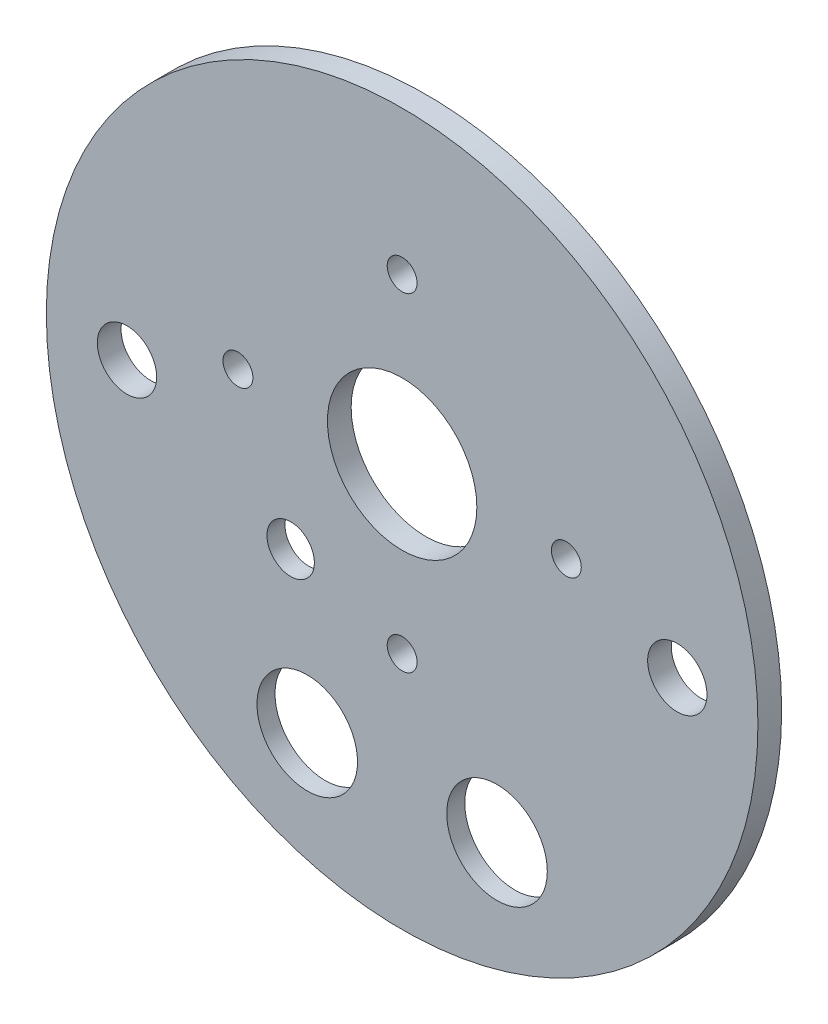
from build123d import *

# Parameters (mm, degrees)
SKETCH1_R           = 49.5046
BOSS_EXTRUDE1_DEPTH = 5.08
SKETCH2_R           = 47.625
BOSS_EXTRUDE2_DEPTH = 3.175
SKETCH3_R           = 6.731
SKETCH3_R_2         = 3.96875
SKETCH3_R_3         = 10
SKETCH3_R_4         = 2
SKETCH3_R_5         = 3.175
CUT_EXTRUDE1_DEPTH  = 9.255
SKETCH7_R           = 52.166274697
CUT_EXTRUDE4_DEPTH  = 5.08
SKETCH8_R           = 11.176
SKETCH8_R_2         = 6.35
CUT_EXTRUDE5_DEPTH  = 0.762


with BuildPart() as part:
    # Sketch1 → Boss-Extrude1 (new body)
    with BuildSketch(Plane.XY):
        Circle(SKETCH1_R)
    extrude(amount=BOSS_EXTRUDE1_DEPTH)

    # Sketch2 → Boss-Extrude2 (add)
    with BuildSketch(Plane.XY.offset(5.08)):
        Circle(SKETCH2_R)
    extrude(amount=BOSS_EXTRUDE2_DEPTH)

    # Sketch3 → Cut-Extrude1 (cut, through all)
    with BuildSketch(Plane.XY.offset(8.255)):
        with Locations((-12.7, -31.166793627)):
            Circle(SKETCH3_R)
        with Locations((12.7, -31.166793627)):
            Circle(SKETCH3_R)
        with Locations((-36.83, 0)):
            Circle(SKETCH3_R_2)
        with Locations((36.83, 0)):
            Circle(SKETCH3_R_2)
        with Locations((0, 6.35)):
            Circle(SKETCH3_R_3)
        with Locations((0, 28.326878759)):
            Circle(SKETCH3_R_4)
        with Locations((21.976878759, 6.35)):
            Circle(SKETCH3_R_4)
        with Locations((0, -15.626878759)):
            Circle(SKETCH3_R_4)
        with Locations((-21.976878759, 6.35)):
            Circle(SKETCH3_R_4)
        with Locations((-14.921345457, -10.968575281)):
            Circle(SKETCH3_R_5)
    extrude(amount=-CUT_EXTRUDE1_DEPTH, mode=Mode.SUBTRACT)

    # Sketch7 → Cut-Extrude4 (cut)
    with BuildSketch(Plane(origin=(0, 0, 0), x_dir=(-1, 0, 0), z_dir=(0, 0, -1))):
        Circle(SKETCH7_R)
    extrude(amount=-CUT_EXTRUDE4_DEPTH, mode=Mode.SUBTRACT)

    # Sketch8 → Cut-Extrude5 (cut)
    with BuildSketch(Plane(origin=(0, 0, 5.08), x_dir=(-1, 0, 0), z_dir=(0, 0, -1))):
        with Locations((-12.7, -31.166793627)):
            Circle(SKETCH8_R)
        with Locations((12.7, -31.166793627)):
            Circle(SKETCH8_R)
        with Locations((14.921345457, -10.968575281)):
            Circle(SKETCH8_R_2)
    extrude(amount=-CUT_EXTRUDE5_DEPTH, mode=Mode.SUBTRACT)


solid = part.part
